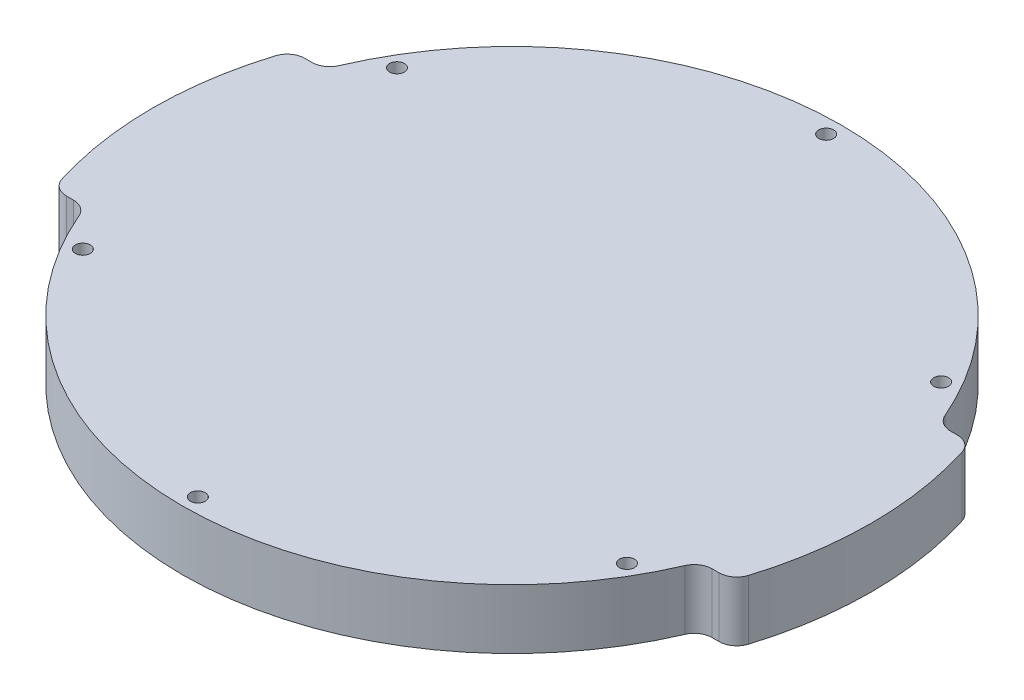
from build123d import *

# Parameters (mm, degrees)
SKETCH_3_R          = 60.3
EXTRUDE_2_DEPTH     = 10
CUT_EXTRUDE_2_DEPTH = 11
FILLET_1_R          = 3
SKETCH_5_R          = 1.25
CUT_EXTRUDE_3_DEPTH = 11


with BuildPart() as part:
    # 草图3 → 凸台-拉伸2 (new body)
    with BuildSketch(Plane(origin=(0, 0, 0), x_dir=(1, 0, 0), z_dir=(0, 1, 0))):
        Circle(SKETCH_3_R)
    extrude(amount=EXTRUDE_2_DEPTH)

    # 草图4 → 切除-拉伸2 (cut, through all)
    with BuildSketch(Plane(origin=(0, 10, 0), x_dir=(1, 0, 0), z_dir=(0, 1, 0))):
        with BuildLine():
            Line((-51.556667852, 20), (-56.886641666, 20))
            ThreePointArc((-56.886641666, 20), (0, 60.3), (56.886641666, 20))
            Line((56.886641666, 20), (51.556667852, 20))
            ThreePointArc((51.556667852, 20), (0, 55.3), (-51.556667852, 20))
        make_face()
        with BuildLine():
            Line((-56.886641666, -20), (-51.556667852, -20))
            ThreePointArc((-51.556667852, -20), (0, -55.3), (51.556667852, -20))
            Line((51.556667852, -20), (56.886641666, -20))
            ThreePointArc((56.886641666, -20), (0, -60.3), (-56.886641666, -20))
        make_face()
    extrude(amount=-CUT_EXTRUDE_2_DEPTH, mode=Mode.SUBTRACT)

    # 圆角1
    fillet_1_edges = [part.edges().sort_by_distance(p)[0] for p in [
        (51.556667852, 5, -20),
        (-51.556667852, 5, -20),
        (-56.886641666, 5, -20),
        (56.886641666, 5, -20),
        (-51.556667852, 5, 20),
        (51.556667852, 5, 20),
        (56.886641666, 5, 20),
        (-56.886641666, 5, 20),
    ]]
    fillet(fillet_1_edges, radius=FILLET_1_R)

    # 草图5 → 切除-拉伸3 (cut, through all)
    with BuildSketch(Plane.XZ):
        with Locations((0, -52.7)):
            Circle(SKETCH_5_R)
        with Locations((-45.639538779, -26.35)):
            Circle(SKETCH_5_R)
        with Locations((-45.639538779, 26.35)):
            Circle(SKETCH_5_R)
        with Locations((0, 52.7)):
            Circle(SKETCH_5_R)
        with Locations((45.639538779, 26.35)):
            Circle(SKETCH_5_R)
        with Locations((45.639538779, -26.35)):
            Circle(SKETCH_5_R)
    extrude(amount=-CUT_EXTRUDE_3_DEPTH, mode=Mode.SUBTRACT)


solid = part.part
